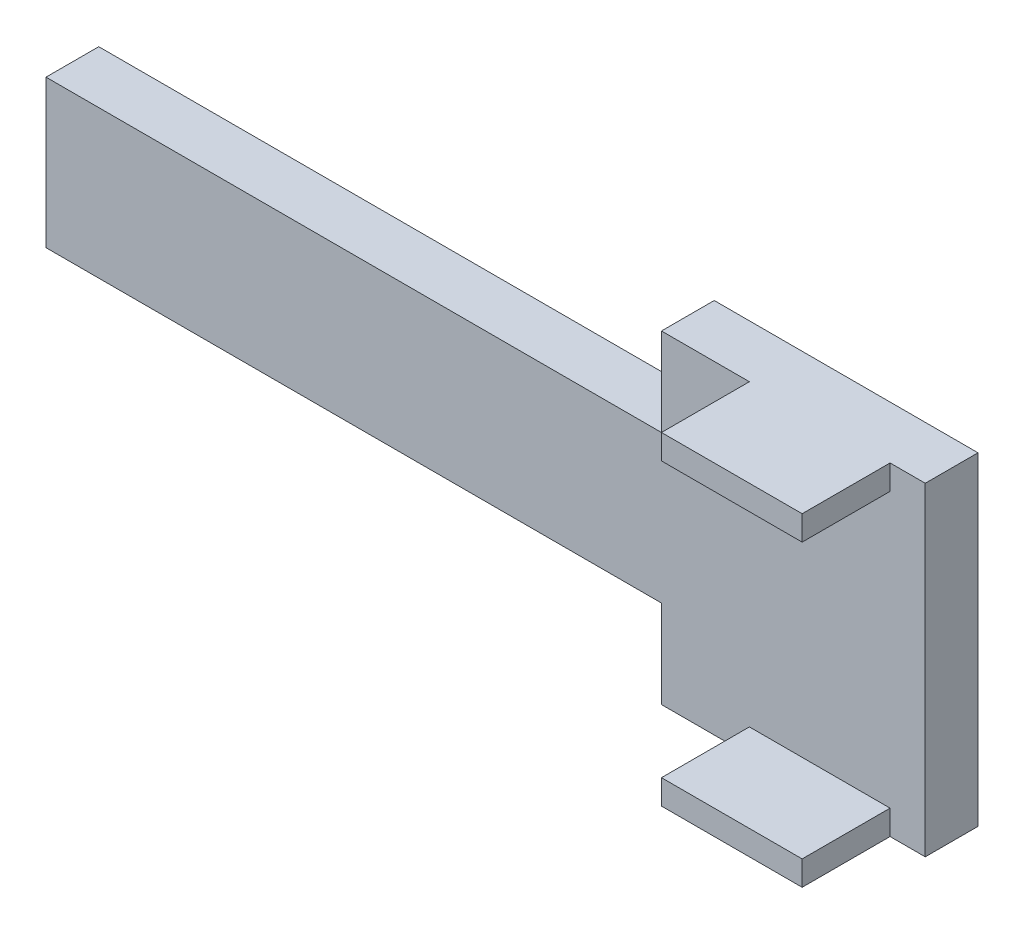
from build123d import *

# Parameters (mm, degrees)
SKETCH2_W           = 63.5
SKETCH2_H           = 23.368
BOSS_EXTRUDE1_DEPTH = 3.81
SKETCH3_W           = 12.7
SKETCH3_H           = 1.778
BOSS_EXTRUDE2_DEPTH = 6.35
SKETCH4_W           = 2.54
SKETCH4_H           = 6.35
CUT_EXTRUDE1_DEPTH  = 24.368
SKETCH5_W           = 44.45
SKETCH5_H           = 6.35
CUT_EXTRUDE2_DEPTH  = 4.81
SCALE1_SCALE        = 1.02


with BuildPart() as part:
    # Sketch2 → Boss-Extrude1 (new body)
    with BuildSketch(Plane.XY):
        Rectangle(SKETCH2_W, SKETCH2_H)
    extrude(amount=BOSS_EXTRUDE1_DEPTH)

    # Sketch3 → Boss-Extrude2 (add)
    with BuildSketch(Plane.XY.offset(3.81)):
        with Locations((25.4, 10.795)):
            Rectangle(SKETCH3_W, SKETCH3_H)
        with Locations((25.4, -10.795)):
            Rectangle(SKETCH3_W, SKETCH3_H)
    extrude(amount=BOSS_EXTRUDE2_DEPTH)

    # Sketch4 → Cut-Extrude1 (cut, through all)
    with BuildSketch(Plane(origin=(0, 11.684, 0), x_dir=(1, 0, 0), z_dir=(0, 1, 0))):
        with Locations((30.48, -6.985)):
            Rectangle(SKETCH4_W, SKETCH4_H)
    extrude(amount=-CUT_EXTRUDE1_DEPTH, mode=Mode.SUBTRACT)

    # Sketch5 → Cut-Extrude2 (cut, through all)
    with BuildSketch(Plane.XY.offset(3.81)):
        with Locations((-9.525, -8.509)):
            Rectangle(SKETCH5_W, SKETCH5_H)
    cut_extrude2 = extrude(amount=-CUT_EXTRUDE2_DEPTH, mode=Mode.SUBTRACT)

    # Mirror1: Cut-Extrude2 across plane
    add(cut_extrude2.mirror(Plane.ZX), mode=Mode.SUBTRACT)


with BuildPart() as part_1:
    # Scale1: scaled about (6.972453348, 0, 2.217272228)
    add(part.part.scale(SCALE1_SCALE).moved(Location((-0.139449067, 0, -0.044345445))))


solid = part_1.part
